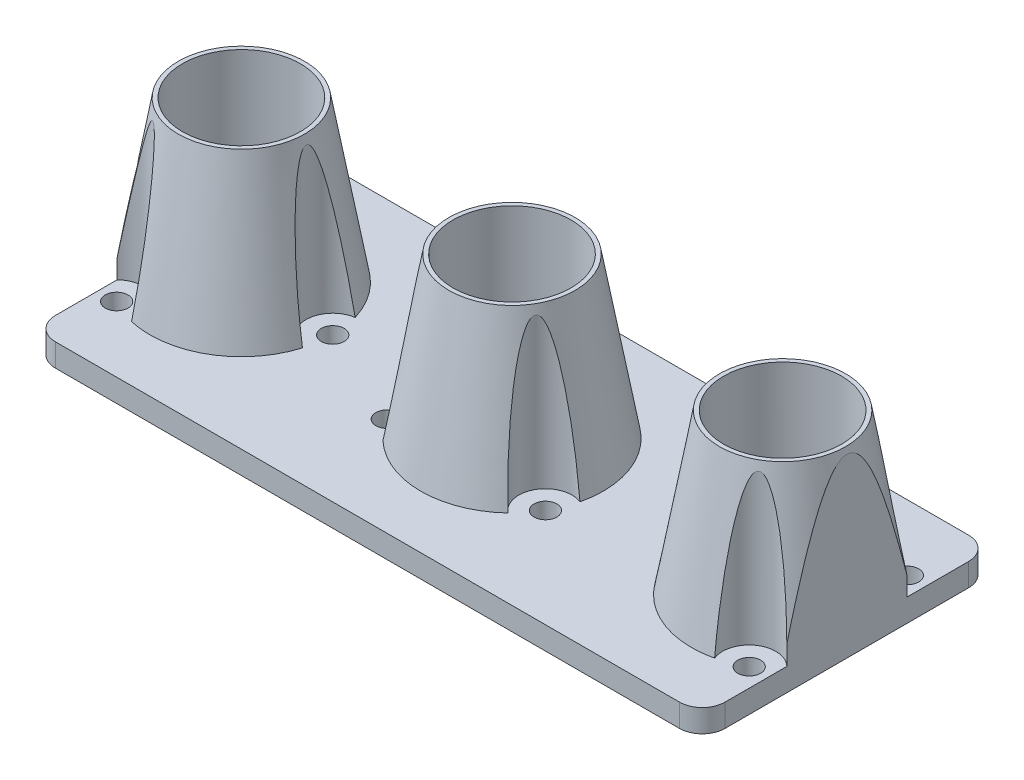
from build123d import *

# Parameters (mm, degrees)
SKETCH1_R           = 7.75
SKETCH1_R_2         = 1.5
BOSS_EXTRUDE1_DEPTH = 3
SKETCH2_R           = 12
BOSS_EXTRUDE2_DEPTH = 21
BOSS_EXTRUDE2_TAPER = 10
SKETCH4_R           = 7.75
SKETCH4_R_2         = 3.5
CUT_EXTRUDE1_DEPTH  = 21
SKETCH5_OUTSIDE_W   = 118.16
SKETCH5_OUTSIDE_H   = 61.04
SKETCH5_OUTSIDE_W_2 = 88
SKETCH5_OUTSIDE_H_2 = 38
CUT_EXTRUDE2_DEPTH  = 22.0000001


with BuildPart() as part:
    # Sketch1 → Boss-Extrude1 (new body)
    with BuildSketch(Plane(origin=(0, 0, 0), x_dir=(1, 0, 0), z_dir=(0, 1, 0))):
        with BuildLine():
            Line((41, 19), (-41, 19))
            ThreePointArc((-41, 19), (-43.121320344, 18.121320344), (-44, 16))
            Line((-44, 16), (-44, -16))
            ThreePointArc((-44, -16), (-43.121320344, -18.121320344), (-41, -19))
            Line((-41, -19), (41, -19))
            ThreePointArc((41, -19), (43.121320344, -18.121320344), (44, -16))
            Line((44, -16), (44, 16))
            ThreePointArc((44, 16), (43.121320344, 18.121320344), (41, 19))
        make_face()
        with Locations((-35.56, 0)):
            Circle(SKETCH1_R, mode=Mode.SUBTRACT)
        Circle(SKETCH1_R, mode=Mode.SUBTRACT)
        with Locations((35.56, 0)):
            Circle(SKETCH1_R, mode=Mode.SUBTRACT)
        with Locations((-23.56, 0)):
            Circle(SKETCH1_R_2, mode=Mode.SUBTRACT)
        with Locations((-41.56, -10.392304845)):
            Circle(SKETCH1_R_2, mode=Mode.SUBTRACT)
        with Locations((-41.56, 10.392304845)):
            Circle(SKETCH1_R_2, mode=Mode.SUBTRACT)
        with Locations((41.56, -10.392304845)):
            Circle(SKETCH1_R_2, mode=Mode.SUBTRACT)
        with Locations((23.56, 0)):
            Circle(SKETCH1_R_2, mode=Mode.SUBTRACT)
        with Locations((41.56, 10.392304845)):
            Circle(SKETCH1_R_2, mode=Mode.SUBTRACT)
        with Locations((0, 12)):
            Circle(SKETCH1_R_2, mode=Mode.SUBTRACT)
        with Locations((10.392304845, -6)):
            Circle(SKETCH1_R_2, mode=Mode.SUBTRACT)
        with Locations((-10.392304845, -6)):
            Circle(SKETCH1_R_2, mode=Mode.SUBTRACT)
    extrude(amount=BOSS_EXTRUDE1_DEPTH)

    # Sketch2 → Boss-Extrude2 (add)
    with BuildSketch(Plane(origin=(0, 3, 0), x_dir=(1, 0, 0), z_dir=(0, 1, 0))):
        with Locations((-35.56, 0)):
            Circle(SKETCH2_R)
        Circle(SKETCH2_R)
        with Locations((35.56, 0)):
            Circle(SKETCH2_R)
    extrude(amount=BOSS_EXTRUDE2_DEPTH, taper=BOSS_EXTRUDE2_TAPER)

    # Sketch4 → Cut-Extrude1 (cut)
    with BuildSketch(Plane(origin=(0, 3, 0), x_dir=(1, 0, 0), z_dir=(0, 1, 0))):
        with Locations((-35.56, 0)):
            Circle(SKETCH4_R)
        Circle(SKETCH4_R)
        with Locations((35.56, 0)):
            Circle(SKETCH4_R)
        with Locations((-41.56, 10.392304845)):
            Circle(SKETCH4_R_2)
        with Locations((-23.56, 0)):
            Circle(SKETCH4_R_2)
        with Locations((-41.56, -10.392304845)):
            Circle(SKETCH4_R_2)
        with Locations((0, 12)):
            Circle(SKETCH4_R_2)
        with Locations((-10.392304845, -6)):
            Circle(SKETCH4_R_2)
        with Locations((10.392304845, -6)):
            Circle(SKETCH4_R_2)
        with Locations((23.56, 0)):
            Circle(SKETCH4_R_2)
        with Locations((41.56, 10.392304845)):
            Circle(SKETCH4_R_2)
        with Locations((41.56, -10.392304845)):
            Circle(SKETCH4_R_2)
    extrude(amount=CUT_EXTRUDE1_DEPTH, mode=Mode.SUBTRACT)

    # Sketch5 outside → Cut-Extrude2 (cut, through all)
    with BuildSketch(Plane(origin=(0, 3, 0), x_dir=(1, 0, 0), z_dir=(0, 1, 0))):
        Rectangle(SKETCH5_OUTSIDE_W, SKETCH5_OUTSIDE_H)
        Rectangle(SKETCH5_OUTSIDE_W_2, SKETCH5_OUTSIDE_H_2, mode=Mode.SUBTRACT)
    extrude(amount=CUT_EXTRUDE2_DEPTH, mode=Mode.SUBTRACT)


solid = part.part
